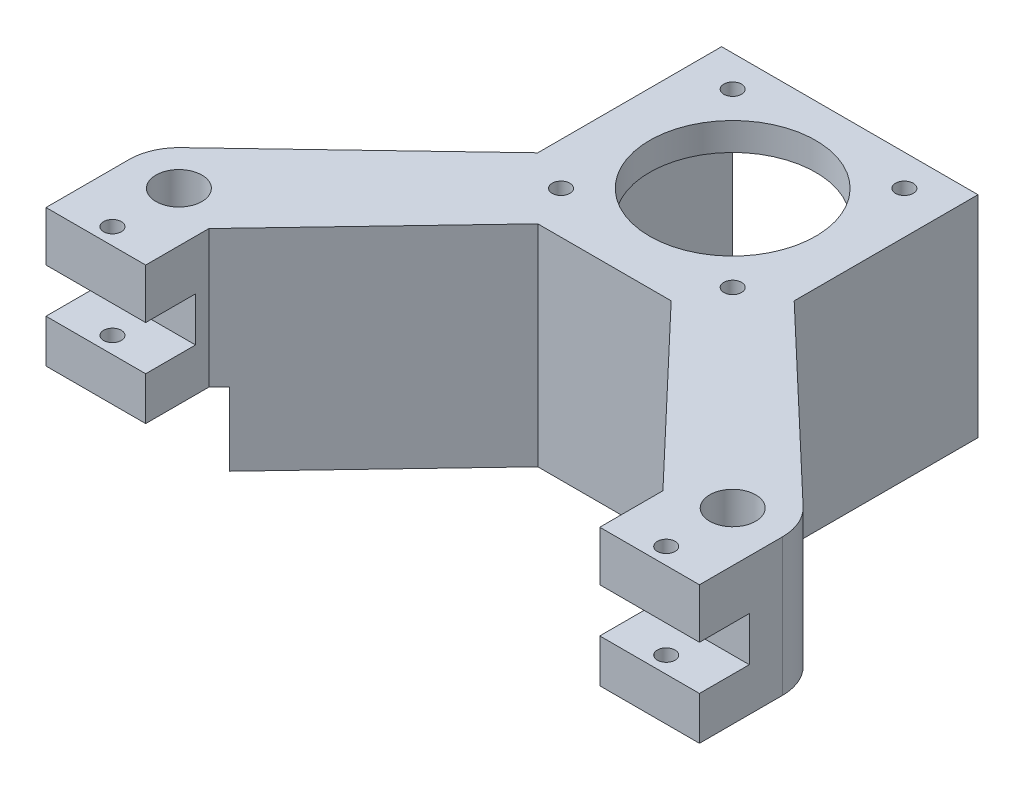
from build123d import *

# Parameters (mm, degrees)
SKETCH_6_W          = 42.3
SKETCH_6_H          = 42.3
SKETCH_6_R          = 1.6
SKETCH_6_R_2        = 15
EXTRUDE_1_DEPTH     = 5
SKETCH_7_R          = 1.6
SKETCH_7_R_2        = 4.15
EXTRUDE_5_DEPTH     = 38
SKETCH_7_7_R        = 4.15
SKETCH_7_7_R_2      = 1.6
EXTRUDE_7_DEPTH     = 38
SKETCH_7_8_R        = 4.15
SKETCH_7_8_R_2      = 1.6
EXTRUDE_8_DEPTH     = 38
SKETCH_12_W         = 2
SKETCH_12_H         = 44.3
EXTRUDE_11_DEPTH    = 38
SKETCH_14_W         = 44.3
SKETCH_14_H         = 2
EXTRUDE_12_DEPTH    = 38
SKETCH_15_W         = 2
SKETCH_15_H         = 42.3
EXTRUDE_13_DEPTH    = 38
SKETCH_17_W         = 20.286999771
SKETCH_17_H         = 45
SKETCH_17_W_2       = 22.63718559
SKETCH_17_H_2       = 42.177300538
CUT_EXTRUDE_1_DEPTH = 13.2
SKETCH_18_W         = 9
SKETCH_18_H         = 8
CUT_EXTRUDE_2_DEPTH = 123


with BuildPart() as part:
    # 草图6 → 凸台-拉伸1 (new body)
    with BuildSketch(Plane(origin=(0, 0, 0), x_dir=(1, 0, 0), z_dir=(0, 1, 0))):
        Rectangle(SKETCH_6_W, SKETCH_6_H)
        with Locations(Location((15.5, 15.5, 0), (0, 0, 270))):
            Circle(SKETCH_6_R, mode=Mode.SUBTRACT)
        with Locations(Location((-15.5, 15.5, 0), (0, 0, 270))):
            Circle(SKETCH_6_R, mode=Mode.SUBTRACT)
        with Locations(Location((-15.5, -15.5, 0), (0, 0, 270))):
            Circle(SKETCH_6_R, mode=Mode.SUBTRACT)
        with Locations(Location((15.5, -15.5, 0), (0, 0, 270))):
            Circle(SKETCH_6_R, mode=Mode.SUBTRACT)
        with Locations(Location((0, 0, 0), (0, 0, 270))):
            Circle(SKETCH_6_R_2, mode=Mode.SUBTRACT)
    extrude(amount=EXTRUDE_1_DEPTH)

    # 草图7 → 凸台-拉伸5 (add)
    with BuildSketch(Plane(origin=(0, 5, 0), x_dir=(1, 0, 0), z_dir=(0, 1, 0))):
        with BuildLine():
            Line((56.202269248, -43.478354795), (21.15, -10.142654247))
            Line((21.15, -10.142654247), (21.15, -21.15))
            Line((21.15, -21.15), (10.142654247, -21.15))
            Line((10.142654247, -21.15), (41, -53.596295528))
            Line((41, -53.596295528), (41, -65))
            Line((41, -65), (59, -65))
            Line((59, -65), (59, -50))
            ThreePointArc((59, -50), (58.271046585, -46.45179082), (56.202269248, -43.478354795))
        make_face()
        with Locations(Location((50, -62, 0), (0, 0, 270))):
            Circle(SKETCH_7_R, mode=Mode.SUBTRACT)
        with Locations(Location((50, -50, 0), (0, 0, 270))):
            Circle(SKETCH_7_R_2, mode=Mode.SUBTRACT)
        with BuildLine():
            Line((-41, -53.596295528), (-10.142654247, -21.15))
            Line((-10.142654247, -21.15), (-21.15, -21.15))
            Line((-21.15, -21.15), (-21.15, -10.142654247))
            Line((-21.15, -10.142654247), (-56.202269248, -43.478354795))
            ThreePointArc((-56.202269248, -43.478354795), (-58.271046585, -46.45179082), (-59, -50))
            Line((-59, -50), (-59, -65))
            Line((-59, -65), (-41, -65))
            Line((-41, -65), (-41, -53.596295528))
        make_face()
        with Locations(Location((-50, -62, 0), (0, 0, 270))):
            Circle(SKETCH_7_R, mode=Mode.SUBTRACT)
        with Locations(Location((-50, -50, 0), (0, 0, 270))):
            Circle(SKETCH_7_R_2, mode=Mode.SUBTRACT)
    extrude(amount=-EXTRUDE_5_DEPTH)


with BuildPart() as extrude_7_tool:
    # 草图7<7> → 凸台-拉伸7 (new body)
    with BuildSketch(Plane(origin=(0, 5, 0), x_dir=(1, 0, 0), z_dir=(0, 1, 0))):
        with Locations(Location((-50, -50, 0), (0, 0, 270))):
            Circle(SKETCH_7_7_R)
        with Locations(Location((50, -50, 0), (0, 0, 270))):
            Circle(SKETCH_7_7_R)
        with Locations(Location((50, -62, 0), (0, 0, 270))):
            Circle(SKETCH_7_7_R_2)
        with Locations(Location((-50, -62, 0), (0, 0, 270))):
            Circle(SKETCH_7_7_R_2)
    extrude(amount=EXTRUDE_7_DEPTH)


with BuildPart() as part_1:
    add(part.part)


with BuildPart() as part_2:
    # 凸台-拉伸7: joined with extrude_7_tool
    add(part_1.part.fuse(extrude_7_tool.part, tol=0.00001))


with BuildPart() as extrude_7_kept_piece:
    # of the separate pieces the step leaves, the one the design keeps (extrude_7_pieces_kept)
    add(part_2.part.solids().sort_by_distance((-10.142654247, 0, 21.15))[0])


with BuildPart() as extrude_8_tool:
    # 草图7<8> → 凸台-拉伸8 (new body)
    with BuildSketch(Plane(origin=(0, 5, 0), x_dir=(1, 0, 0), z_dir=(0, 1, 0))):
        with Locations(Location((-50, -50, 0), (0, 0, 270))):
            Circle(SKETCH_7_8_R)
        with Locations(Location((50, -50, 0), (0, 0, 270))):
            Circle(SKETCH_7_8_R)
        with Locations(Location((50, -62, 0), (0, 0, 270))):
            Circle(SKETCH_7_8_R_2)
        with Locations(Location((-50, -62, 0), (0, 0, 270))):
            Circle(SKETCH_7_8_R_2)
    extrude(amount=EXTRUDE_8_DEPTH)


with BuildPart() as extrude_7_kept_piece_1:
    add(extrude_7_kept_piece.part)


with BuildPart() as extrude_7_kept_piece_2:
    # 凸台-拉伸8: joined with extrude_8_tool
    add(extrude_7_kept_piece_1.part.fuse(extrude_8_tool.part, tol=0.00001))


with BuildPart() as extrude_8_kept_piece:
    # of the separate pieces the step leaves, the one the design keeps (extrude_8_pieces_kept)
    add(extrude_7_kept_piece_2.part.solids().sort_by_distance((-10.142654247, 0, 21.15))[0])

    # 草图12 → 凸台-拉伸11 (add)
    with BuildSketch(Plane(origin=(0, 5, 0), x_dir=(1, 0, 0), z_dir=(0, 1, 0))):
        with Locations((22.15, -1)):
            Rectangle(SKETCH_12_W, SKETCH_12_H)
    extrude(amount=-EXTRUDE_11_DEPTH)

    # 草图14 → 凸台-拉伸12 (add)
    with BuildSketch(Plane(origin=(0, 5, 0), x_dir=(1, 0, 0), z_dir=(0, 1, 0))):
        with Locations((-1, -22.15)):
            Rectangle(SKETCH_14_W, SKETCH_14_H)
    extrude(amount=-EXTRUDE_12_DEPTH)

    # 草图15 → 凸台-拉伸13 (add)
    with BuildSketch(Plane(origin=(0, 5, 0), x_dir=(1, 0, 0), z_dir=(0, 1, 0))):
        with Locations((-22.15, 0)):
            Rectangle(SKETCH_15_W, SKETCH_15_H)
    extrude(amount=-EXTRUDE_13_DEPTH)

    # 草图17 → 切除-拉伸1 (cut)
    with BuildSketch(Plane.XZ.offset(33)):
        with Locations((49.343499886, 42.5)):
            Rectangle(SKETCH_17_W, SKETCH_17_H)
        with Locations((-50.518592795, 44.367414657)):
            Rectangle(SKETCH_17_W_2, SKETCH_17_H_2)
    extrude(amount=-CUT_EXTRUDE_1_DEPTH, mode=Mode.SUBTRACT)

    # 草图18 → 切除-拉伸2 (cut)
    with BuildSketch(Plane(origin=(59, 0, 0), x_dir=(0, 0, -1), z_dir=(1, 0, 0))):
        with Locations((-60.5, -8)):
            Rectangle(SKETCH_18_W, SKETCH_18_H)
    extrude(amount=-CUT_EXTRUDE_2_DEPTH, mode=Mode.SUBTRACT)


solid = extrude_8_kept_piece.part
